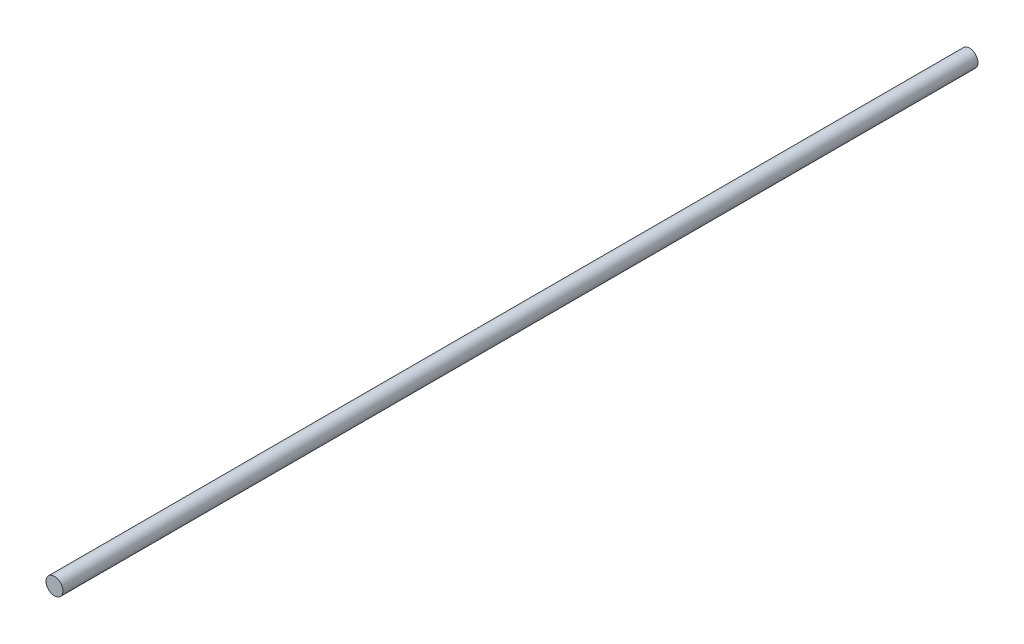
from build123d import *

# Parameters (mm, degrees)
SKETCH1_R           = 5
BOSS_EXTRUDE1_DEPTH = 540


with BuildPart() as part:
    # Sketch1 → Boss-Extrude1 (new body)
    with BuildSketch(Plane.XY):
        Circle(SKETCH1_R)
    extrude(amount=BOSS_EXTRUDE1_DEPTH)


solid = part.part
